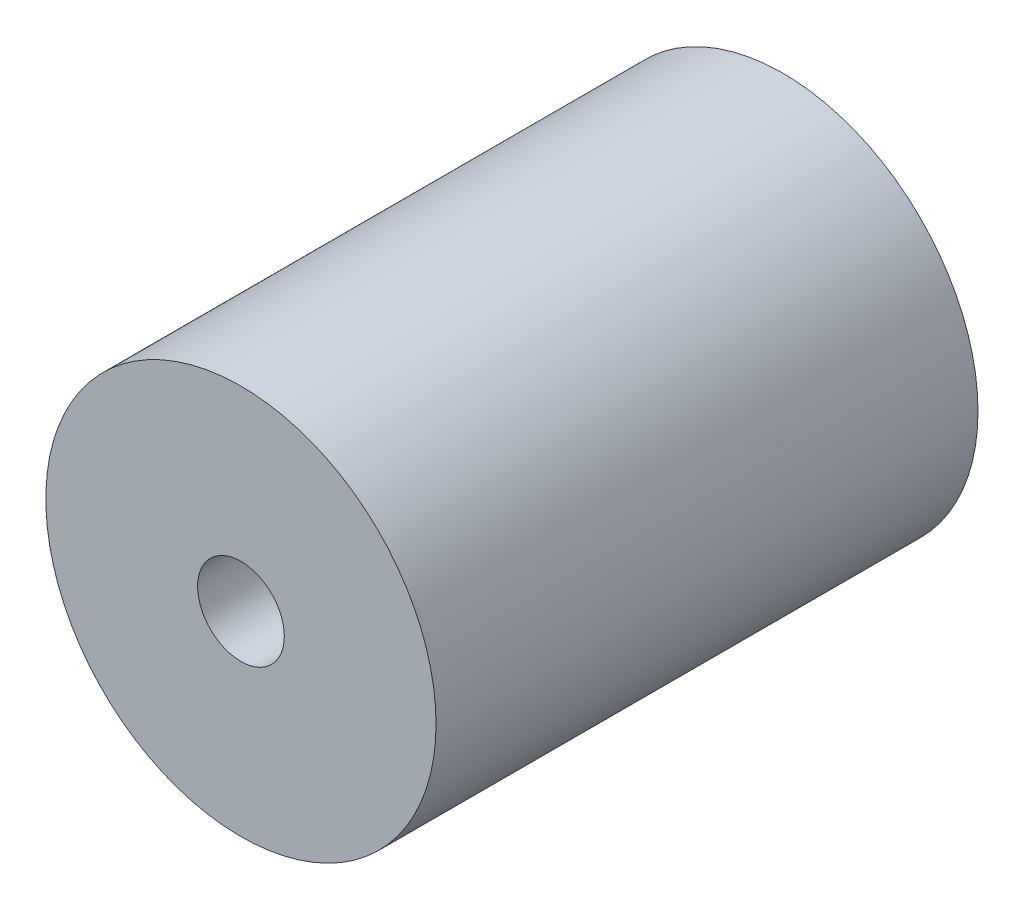
from build123d import *

# Parameters (mm, degrees)
SKETCH1_R           = 9
BOSS_EXTRUDE1_DEPTH = 12.5
CUT_EXTRUDE1_START  = -12.5
SKETCH2_R           = 2
CUT_EXTRUDE1_DEPTH  = 12.5
CUT_EXTRUDE2_START  = -12.5
SKETCH3_R           = 4
CUT_EXTRUDE2_DEPTH  = 12.5


with BuildPart() as part:
    # Sketch1 → Boss-Extrude1 (new body, symmetric)
    with BuildSketch(Plane.XY):
        Circle(SKETCH1_R)
    extrude(amount=BOSS_EXTRUDE1_DEPTH, both=True)

    # Sketch2 → Cut-Extrude1 (cut)
    with BuildSketch(Plane.XY.offset(12.5).offset(CUT_EXTRUDE1_START)):
        Circle(SKETCH2_R)
    extrude(amount=CUT_EXTRUDE1_DEPTH, mode=Mode.SUBTRACT)

    # Sketch3 → Cut-Extrude2 (cut)
    with BuildSketch(Plane(origin=(0, 0, -12.5), x_dir=(-1, 0, 0), z_dir=(0, 0, -1)).offset(CUT_EXTRUDE2_START)):
        Circle(SKETCH3_R)
    extrude(amount=CUT_EXTRUDE2_DEPTH, mode=Mode.SUBTRACT)


solid = part.part
